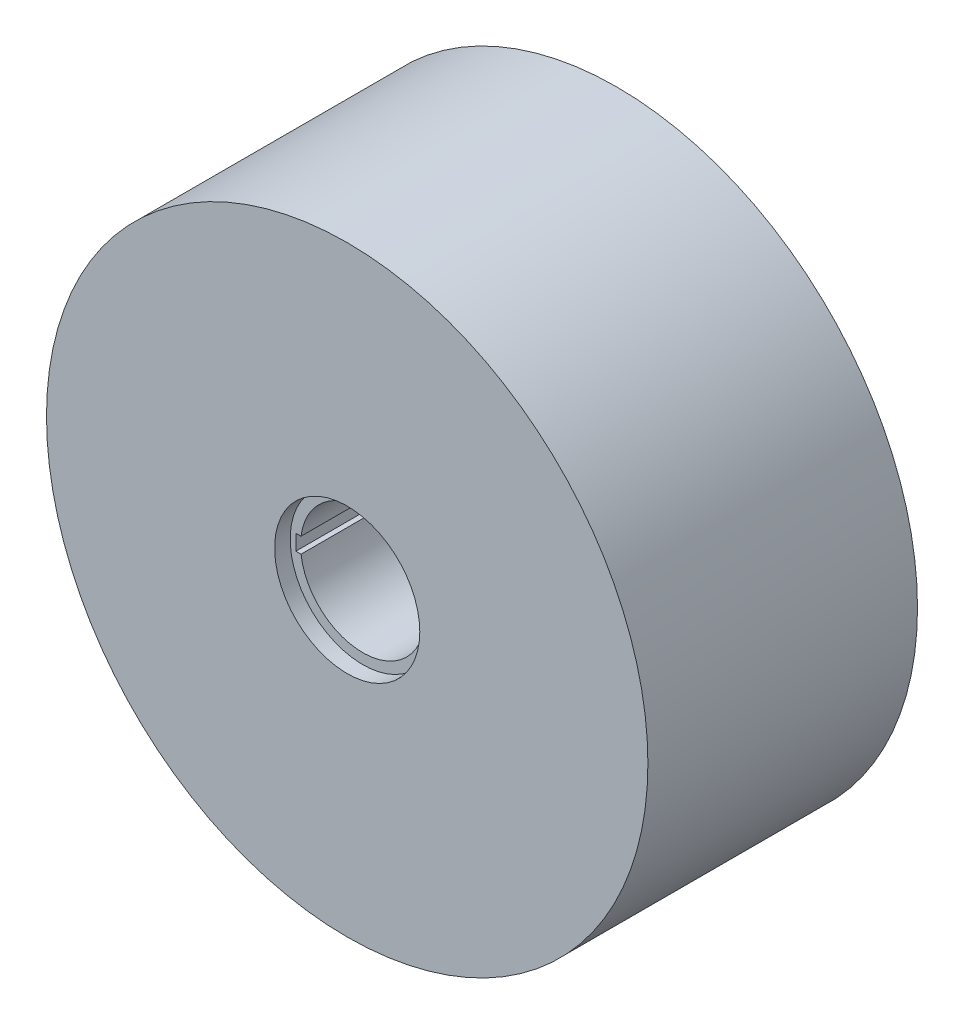
from build123d import *

# Parameters (mm, degrees)
BOSS_EXTRUDE1_DEPTH      = 13
BOSS_EXTRUDE1_DEPTH_BACK = 13
SKETCH1_R                = 29
SKETCH2_R                = 7
CUT_EXTRUDE1_DEPTH       = 1.5


with BuildPart() as part:
    # Sketch1 → Boss-Extrude1 (new, two sides: drawn at the far end of the back side and taken through both)
    with BuildSketch(Plane.XY.offset(-BOSS_EXTRUDE1_DEPTH_BACK)):
        Circle(SKETCH1_R)
        with BuildLine():
            Line((-5.95294045, 0.75), (-6.45294045, 0.75))
            Line((-6.45294045, 0.75), (-6.45294045, -0.75))
            Line((-6.45294045, -0.75), (-5.95294045, -0.75))
            ThreePointArc((-5.95294045, -0.75), (6, 0), (-5.95294045, 0.75))
        make_face(mode=Mode.SUBTRACT)
    extrude(amount=BOSS_EXTRUDE1_DEPTH + BOSS_EXTRUDE1_DEPTH_BACK)

    # Sketch2 → Cut-Extrude1 (cut)
    with BuildSketch(Plane.XY.offset(13)):
        Circle(SKETCH2_R)
    cut_extrude1 = extrude(amount=-CUT_EXTRUDE1_DEPTH, mode=Mode.SUBTRACT)

    # Mirror1: Cut-Extrude1 across plane
    add(cut_extrude1.mirror(Plane.XY), mode=Mode.SUBTRACT)


solid = part.part
